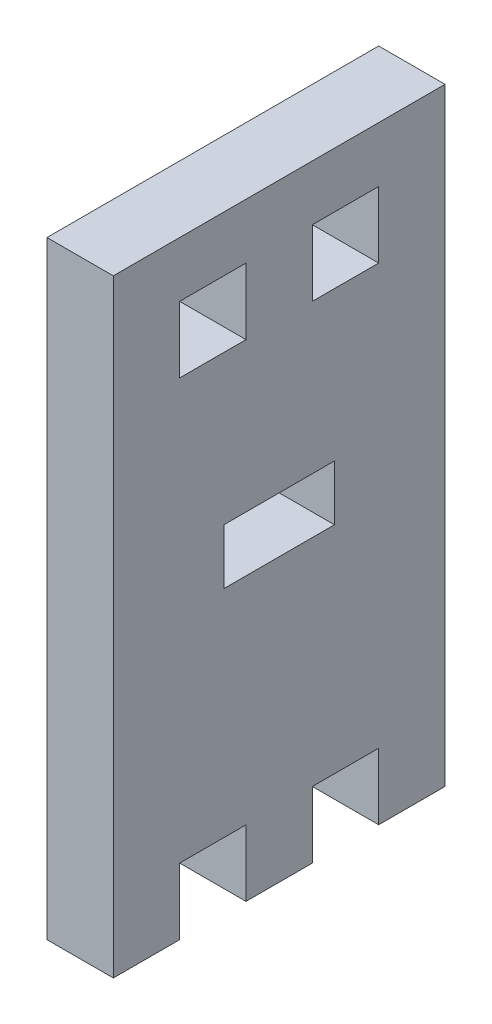
from build123d import *

# Parameters (mm, degrees)
SKETCH1_W           = 6
SKETCH1_H           = 6
SKETCH1_W_2         = 10
SKETCH1_H_2         = 5
BOSS_EXTRUDE1_DEPTH = 6


with BuildPart() as part:
    # Sketch1 → Boss-Extrude1 (new body)
    with BuildSketch(Plane(origin=(0, 0, 0), x_dir=(0, 0, -1), z_dir=(1, 0, 0))):
        Polygon((-15, 27.5), (15, 27.5), (15, -27.5), (9, -27.5), (9, -21.5), (3, -21.5), (3, -27.5), (-3, -27.5), (-3, -21.5), (-9, -21.5), (-9, -27.5), (-15, -27.5), align=None)
        with Locations((-6, 19.5)):
            Rectangle(SKETCH1_W, SKETCH1_H, mode=Mode.SUBTRACT)
        with Locations((6, 19.5)):
            Rectangle(SKETCH1_W, SKETCH1_H, mode=Mode.SUBTRACT)
        with Locations((0, 0.5)):
            Rectangle(SKETCH1_W_2, SKETCH1_H_2, mode=Mode.SUBTRACT)
    extrude(amount=BOSS_EXTRUDE1_DEPTH)


solid = part.part
